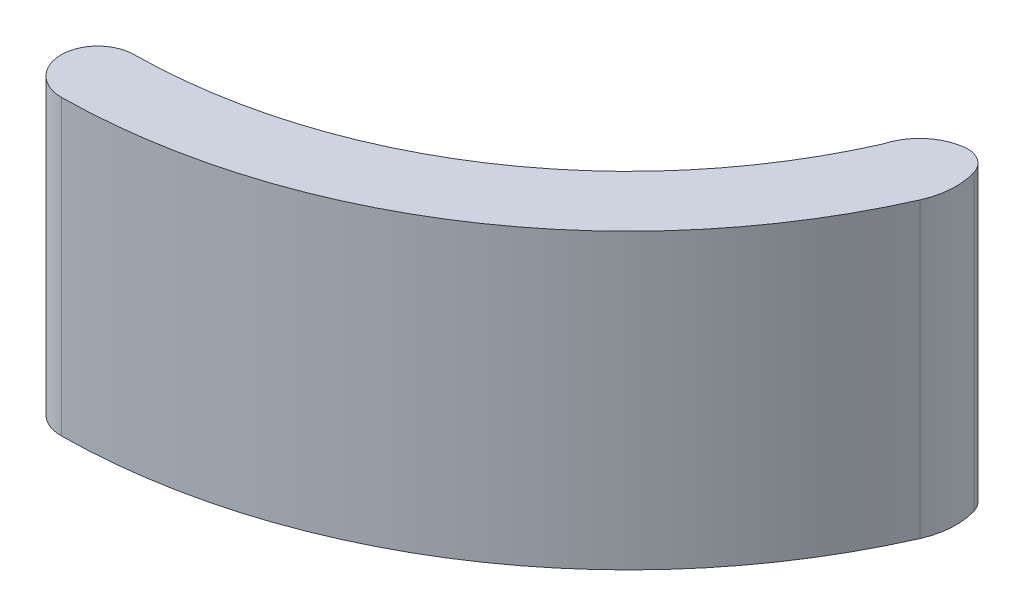
from build123d import *

# Parameters (mm, degrees)
BOSS_EXTRUDE2_DEPTH = 24
FILLET3_R           = 2


with BuildPart() as part:
    # Sketch2 → Boss-Extrude2 (new body)
    with BuildSketch(Plane(origin=(0, 0, 0), x_dir=(1, 0, 0), z_dir=(0, 1, 0))):
        with BuildLine():
            ThreePointArc((64.008898715, 11.143267641), (64.514374858, 13.892879926), (63.719057289, 16.573056006))
            ThreePointArc((63.719057289, 16.573056006), (60.499660734, 16.149214409), (58.522904866, 13.573056006))
            ThreePointArc((58.522904866, 13.573056006), (43.615754555, -4.011786119), (21.55946325, -10.71773995))
            ThreePointArc((21.55946325, -10.71773995), (18.586355818, -13.744393581), (21.613009449, -16.717501013))
            ThreePointArc((21.613009449, -16.717501013), (46.910872497, -9.025985731), (64.008898715, 11.143267641))
        make_face()
    extrude(amount=BOSS_EXTRUDE2_DEPTH)

    # Fillet3
    fillet3_edges = [part.edges().sort_by_distance(p)[0] for p in [
        (63.719057289, 12, -16.573056006),
    ]]
    fillet(fillet3_edges, radius=FILLET3_R)


solid = part.part
